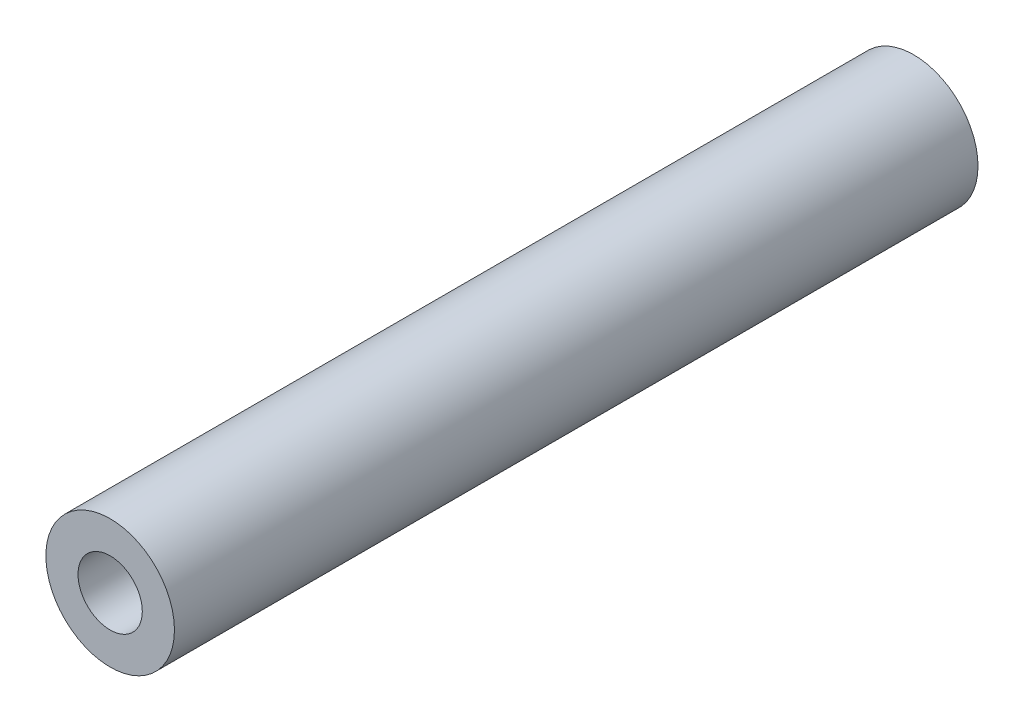
from build123d import *

# Parameters (mm, degrees)
SKETCH_1_R      = 2
SKETCH_1_R_2    = 1
EXTRUDE_1_DEPTH = 12.5


with BuildPart() as part:
    # 草图1 → 凸台-拉伸1 (new body, symmetric)
    with BuildSketch(Plane.XY):
        Circle(SKETCH_1_R)
        Circle(SKETCH_1_R_2, mode=Mode.SUBTRACT)
    extrude(amount=EXTRUDE_1_DEPTH, both=True)


solid = part.part
